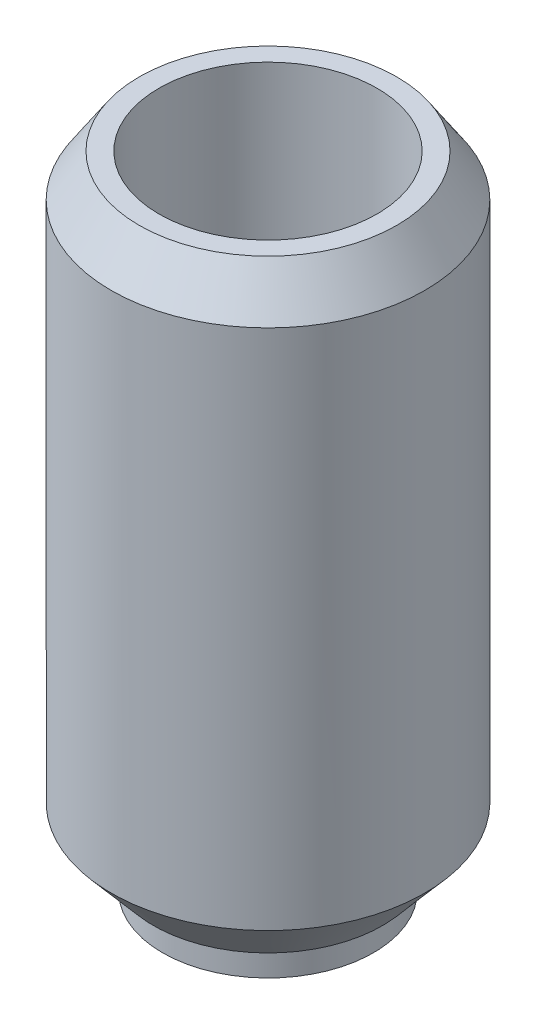
from build123d import *

# Parameters (mm, degrees)
ESQUISSE1_R             = 11.15
BOSS_EXTRU_1_DEPTH      = 45.6
ESQUISSE2_R             = 7.75
ENL_V_MAT_EXTRU_1_DEPTH = 33
ESQUISSE3_R             = 11.15
ESQUISSE3_R_2           = 7.5
ENL_V_MAT_EXTRU_2_DEPTH = 2
ESQUISSE4_R             = 3.75
ENL_V_MAT_EXTRU_3_DEPTH = 46.6
CHANFREIN1_SIZE         = 3
CHANFREIN1_SIZE2        = 2
CHANFREIN2_SIZE         = 3.5
CHANFREIN2_SIZE2        = 3


with BuildPart() as part:
    # Esquisse1 → Boss.-Extru.1 (new body)
    with BuildSketch(Plane(origin=(0, 0, 0), x_dir=(1, 0, 0), z_dir=(0, 1, 0))):
        Circle(ESQUISSE1_R)
    extrude(amount=BOSS_EXTRU_1_DEPTH)

    # Esquisse2 → Enlèv. mat.-Extru.1 (cut)
    with BuildSketch(Plane(origin=(0, 45.6, 0), x_dir=(1, 0, 0), z_dir=(0, 1, 0))):
        Circle(ESQUISSE2_R)
    extrude(amount=-ENL_V_MAT_EXTRU_1_DEPTH, mode=Mode.SUBTRACT)

    # Esquisse3 → Enlèv. mat.-Extru.2 (cut)
    with BuildSketch(Plane.XZ):
        Circle(ESQUISSE3_R)
        Circle(ESQUISSE3_R_2, mode=Mode.SUBTRACT)
    extrude(amount=-ENL_V_MAT_EXTRU_2_DEPTH, mode=Mode.SUBTRACT)

    # Esquisse4 → Enlèv. mat.-Extru.3 (cut, through all)
    with BuildSketch(Plane.XZ):
        Circle(ESQUISSE4_R)
    extrude(amount=-ENL_V_MAT_EXTRU_3_DEPTH, mode=Mode.SUBTRACT)

    # Chanfrein1
    chanfrein1_edges = [part.edges().sort_by_distance(p)[0] for p in [
        (-11.15, 45.6, 0),
    ]]
    chanfrein1_side = [part.faces().sort_by_distance(p)[0] for p in [
        (-11.15, 23.8, 0),
    ]]
    chamfer(chanfrein1_edges, length=CHANFREIN1_SIZE, length2=CHANFREIN1_SIZE2, reference=chanfrein1_side[0])

    # Chanfrein2
    chanfrein2_edges = [part.edges().sort_by_distance(p)[0] for p in [
        (-11.15, 2, 0),
    ]]
    chanfrein2_side = [part.faces().sort_by_distance(p)[0] for p in [
        (-11.15, 22.3, 0),
    ]]
    chamfer(chanfrein2_edges, length=CHANFREIN2_SIZE, length2=CHANFREIN2_SIZE2, reference=chanfrein2_side[0])


solid = part.part
